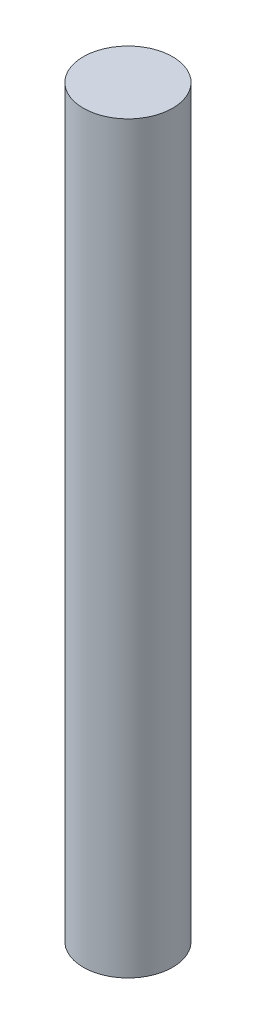
from build123d import *

# Parameters (mm, degrees)
SKETCH1_R           = 9.525
BOSS_EXTRUDE1_DEPTH = 158.75


with BuildPart() as part:
    # Sketch1 → Boss-Extrude1 (new body)
    with BuildSketch(Plane(origin=(0, 0, 0), x_dir=(1, 0, 0), z_dir=(0, 1, 0))):
        Circle(SKETCH1_R)
    extrude(amount=BOSS_EXTRUDE1_DEPTH)


solid = part.part
